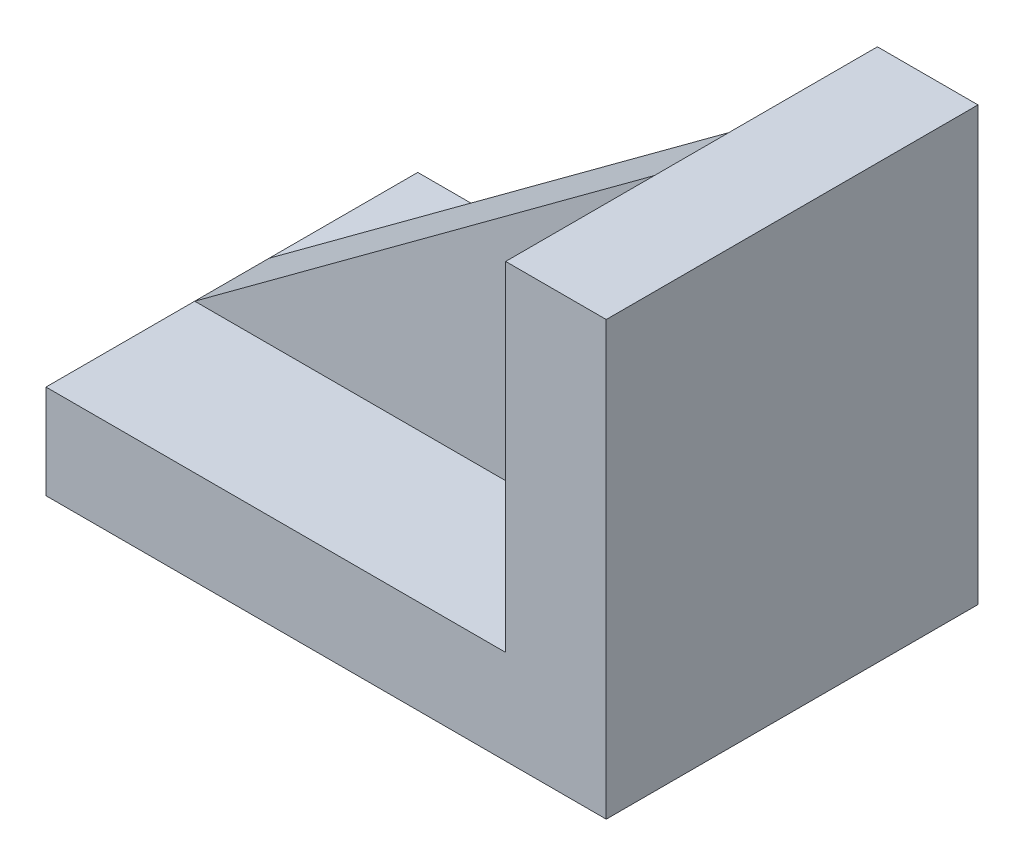
from build123d import *

# Parameters (mm, degrees)
BOSS_EXTRUDE2_DEPTH = 25
RIB4_REACH          = 82.75
SKETCH2_WALL_W      = 240.282714568
SKETCH2_WALL_H      = 10


with BuildPart() as part:
    # Sketch1 → Boss-Extrude2 (new, symmetric)
    with BuildSketch(Plane.XY):
        Polygon((0, 0), (-61.820224508, 0), (-61.820224508, -12.662921305), (0, -12.662921305), (13.528089841, -12.662921305), (13.528089841, 45.539325687), (0, 45.539325687), align=None)
    extrude(amount=BOSS_EXTRUDE2_DEPTH, both=True)

    # Sketch2 wall → Rib4 (add, up to next)
    with BuildSketch(Plane(origin=(-30.910112254, 22.769662844, 0), x_dir=(-0.805133069987, -0.593094208042, 0), z_dir=(0.593094208042, -0.805133069987, 0)), mode=Mode.PRIVATE) as rib4_sk1:
        Rectangle(SKETCH2_WALL_W, SKETCH2_WALL_H)
    rib4_tool1 = extrude(rib4_sk1.sketch, amount=RIB4_REACH, mode=Mode.PRIVATE) - part.part
    add(rib4_tool1.solids().sort_by_distance((-30.910112254, 22.769662844, 0))[0])


solid = part.part
